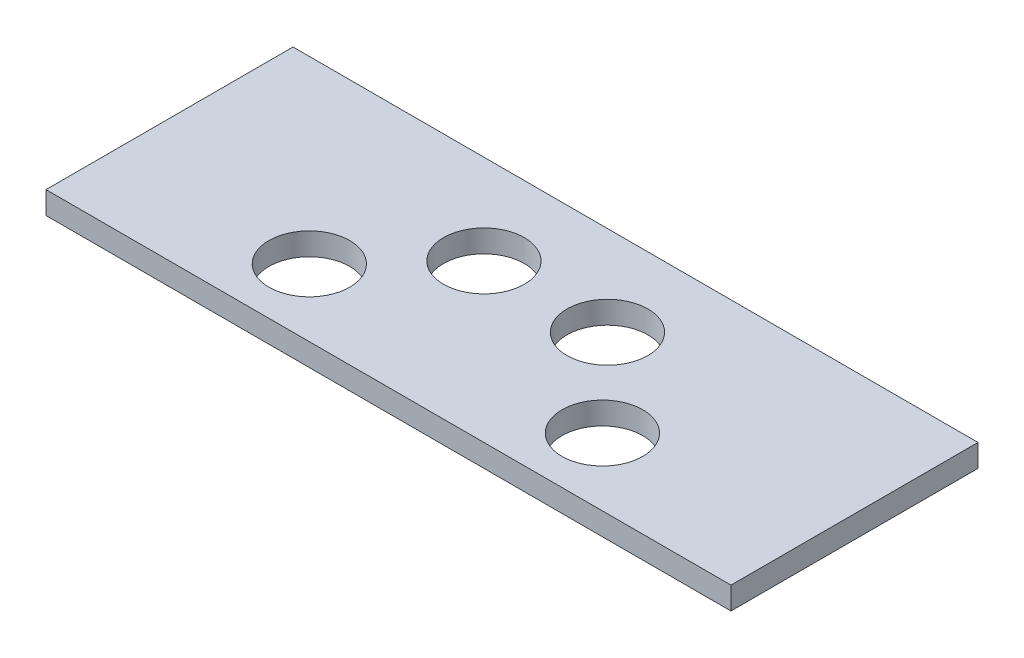
from build123d import *

# Parameters (mm, degrees)
SKETCH1_W           = 30.5
SKETCH1_H           = 11
SKETCH1_R           = 1.8
BOSS_EXTRUDE1_DEPTH = 1


with BuildPart() as part:
    # Sketch1 → Boss-Extrude1 (new body)
    with BuildSketch(Plane(origin=(0, 0, 0), x_dir=(1, 0, 0), z_dir=(0, 1, 0))):
        with Locations((-3.144949305, 2.635460251)):
            Rectangle(SKETCH1_W, SKETCH1_H)
        with Locations(Location((-5.894949305, 4.135460251, 0), (0, 0, 270))):  # turned: the seam where the file's is
            Circle(SKETCH1_R, mode=Mode.SUBTRACT)
        with Locations(Location((-0.394949305, 4.135460251, 0), (0, 0, 270))):  # turned: the seam where the file's is
            Circle(SKETCH1_R, mode=Mode.SUBTRACT)
        with Locations(Location((-9.669866522, 0.135460251, 0), (0, 0, 270))):  # turned: the seam where the file's is
            Circle(SKETCH1_R, mode=Mode.SUBTRACT)
        with Locations(Location((3.379967913, 0.135460251, 0), (0, 0, 270))):  # turned: the seam where the file's is
            Circle(SKETCH1_R, mode=Mode.SUBTRACT)
    extrude(amount=BOSS_EXTRUDE1_DEPTH)


solid = part.part
